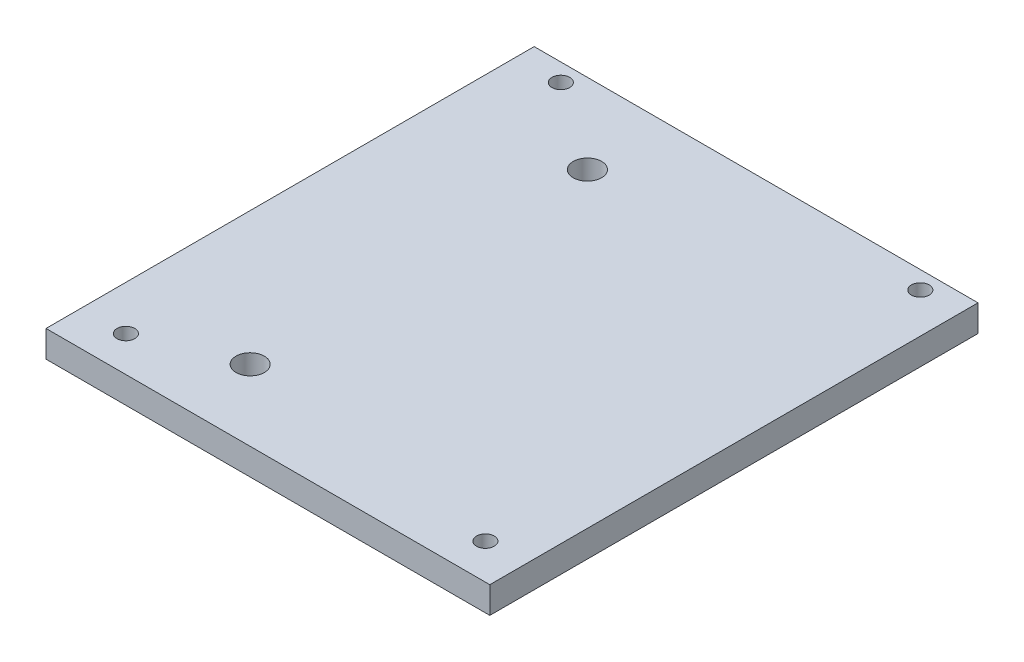
from build123d import *

# Parameters (mm, degrees)
SKETCH1_W           = 50
SKETCH1_H           = 55
SKETCH1_R           = 1.6
SKETCH1_R_2         = 1
BOSS_EXTRUDE1_DEPTH = 3


with BuildPart() as part:
    # Sketch1 → Boss-Extrude1 (new body)
    with BuildSketch(Plane(origin=(0, 0, 0), x_dir=(1, 0, 0), z_dir=(0, 1, 0))):
        with Locations((-19.511008016, 1.684795776)):
            Rectangle(SKETCH1_W, SKETCH1_H)
        with Locations((-29.511008016, 20.184795776)):
            Circle(SKETCH1_R, mode=Mode.SUBTRACT)
        with Locations((-29.511008016, -17.815204224)):
            Circle(SKETCH1_R, mode=Mode.SUBTRACT)
        with Locations((-39.511008016, 27.184795776)):
            Circle(SKETCH1_R_2, mode=Mode.SUBTRACT)
        with Locations((-39.511008016, -21.815204224)):
            Circle(SKETCH1_R_2, mode=Mode.SUBTRACT)
        with Locations((0.988991984, -21.815204224)):
            Circle(SKETCH1_R_2, mode=Mode.SUBTRACT)
        with Locations((0.988991984, 27.184795776)):
            Circle(SKETCH1_R_2, mode=Mode.SUBTRACT)
    extrude(amount=BOSS_EXTRUDE1_DEPTH)


solid = part.part
